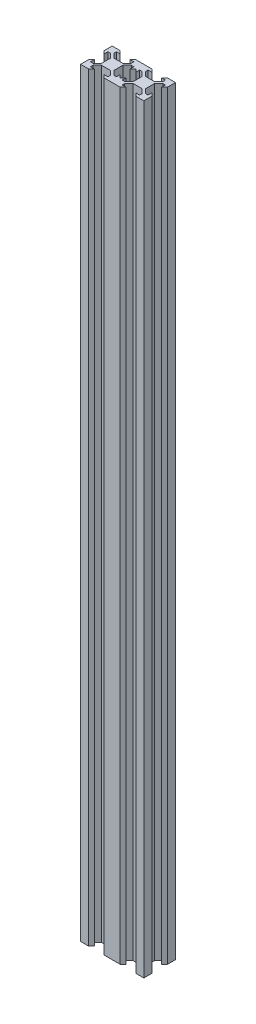
from build123d import *

# Parameters (mm, degrees)
BOSS_EXTRUDE1_DEPTH = 480
LPATTERN1_COUNT     = 2
LPATTERN1_PITCH     = 20


with BuildPart() as part:
    # Sketch1 → Boss-Extrude1 (new body)
    with BuildSketch(Plane(origin=(0, 0, 0), x_dir=(1, 0, 0), z_dir=(0, 1, 0))):
        Polygon((2.84, -3.900660172), (-2.84, -3.900660172), (-5.499339828, -6.56), (-5.499339828, -8.2), (-3.1, -8.2), (-4.9, -10), (-10, -10), (-10, -4.9), (-8.2, -3.1), (-8.2, -5.499339828), (-6.56, -5.499339828), (-3.900660172, -2.84), (-3.900660172, 2.84), (-6.56, 5.499339828), (-8.2, 5.499339828), (-8.2, 3.1), (-10, 4.9), (-10, 10), (-4.9, 10), (-3.1, 8.2), (-5.499339828, 8.2), (-5.499339828, 6.56), (-2.84, 3.900660172), (2.84, 3.900660172), (5.499339828, 6.56), (5.499339828, 8.2), (3.1, 8.2), (4.9, 10), (10, 10), (10, 4.9), (8.2, 3.1), (8.2, 5.499339828), (6.56, 5.499339828), (3.900660172, 2.84), (3.900660172, -2.84), (6.56, -5.499339828), (8.2, -5.499339828), (8.2, -3.1), (10, -4.9), (10, -10), (4.9, -10), (3.1, -8.2), (5.499339828, -8.2), (5.499339828, -6.56), align=None)
    boss_extrude1 = extrude(amount=BOSS_EXTRUDE1_DEPTH)

    # LPattern1: Boss-Extrude1 ×2
    with Locations(*[(i * LPATTERN1_PITCH, 0, 0) for i in range(1, LPATTERN1_COUNT)]):
        add(boss_extrude1)


solid = part.part
